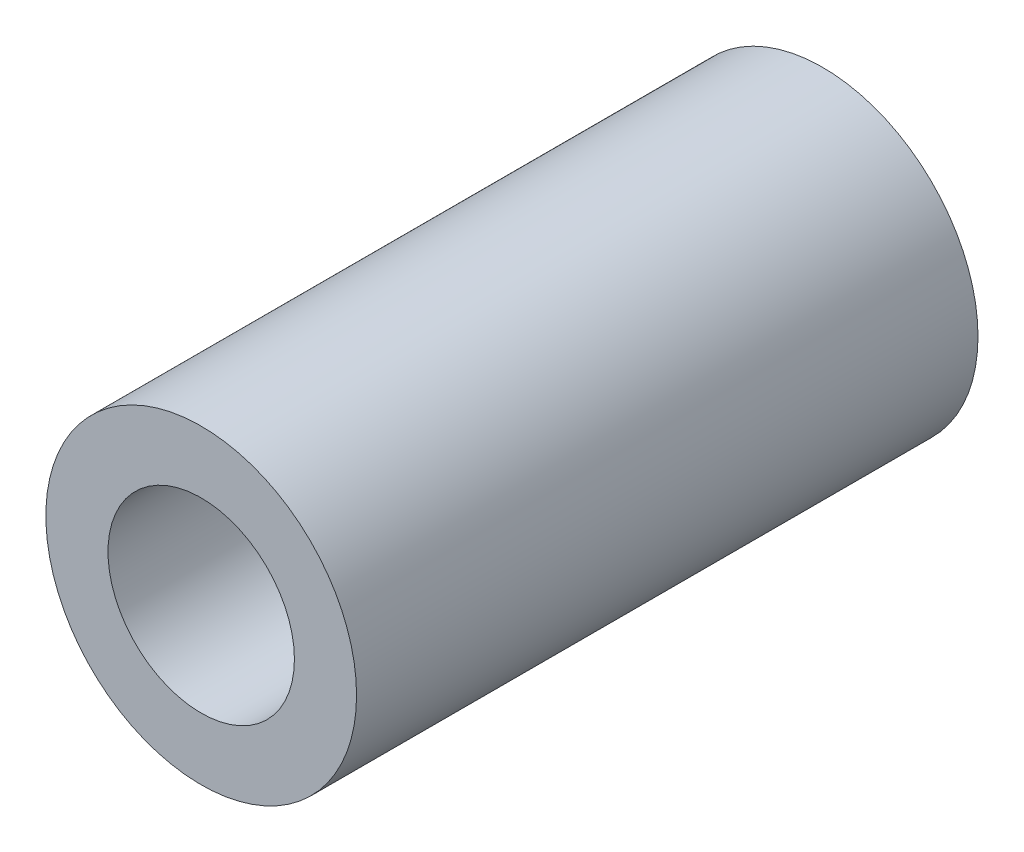
from build123d import *

# Parameters (mm, degrees)
ESQUISSE1_R        = 5
ESQUISSE1_R_2      = 3
BOSS_EXTRU_1_DEPTH = 20


with BuildPart() as part:
    # Esquisse1 → Boss.-Extru.1 (new body)
    with BuildSketch(Plane.XY):
        Circle(ESQUISSE1_R)
        Circle(ESQUISSE1_R_2, mode=Mode.SUBTRACT)
    extrude(amount=BOSS_EXTRU_1_DEPTH)


solid = part.part
